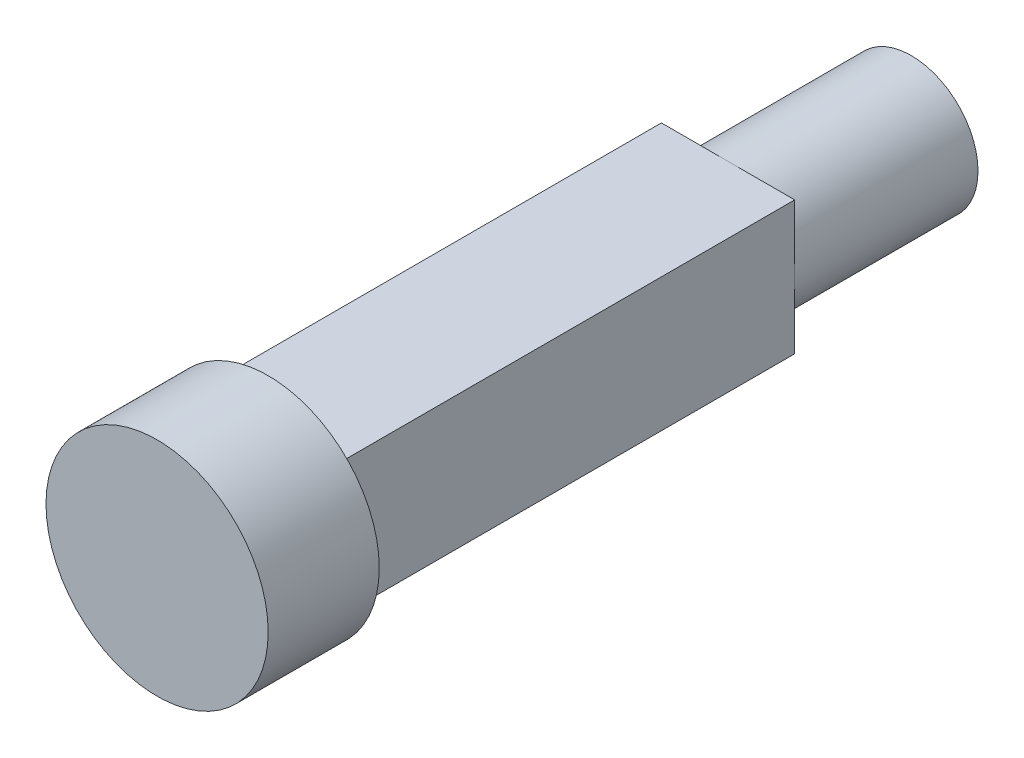
from build123d import *

# Parameters (mm, degrees)
ESQUISSE6_W             = 6
ESQUISSE6_H             = 6
BOSS_EXTRU_2_DEPTH      = 20.7
ENL_V_MAT_EXTRU_1_DEPTH = 10


with BuildPart() as part:
    # Esquisse2 → Révolution1 (revolve)
    with BuildSketch(Plane(origin=(0, 0, 0), x_dir=(0, 0, -1), z_dir=(1, 0, 0))):
        Polygon((0, 0), (33.95, 0), (33.95, 3), (5, 3), (5, 5), (0, 5), align=None)
    revolve(axis=Axis((0, 0, 0), (0, 0, -1)))

    # Esquisse6 → Boss.-Extru.2 (add)
    with BuildSketch(Plane(origin=(0, 0, -5), x_dir=(-1, 0, 0), z_dir=(0, 0, -1))):
        Rectangle(ESQUISSE6_W, ESQUISSE6_H)
    extrude(amount=BOSS_EXTRU_2_DEPTH)

    # Esquisse4 → Enlèv. mat.-Extru.1 (cut)
    with BuildSketch(Plane(origin=(0, 0, -33.95), x_dir=(-1, 0, 0), z_dir=(0, 0, -1))):
        with BuildLine():
            Line((-1.204159458, 1.2), (1.204159458, 1.2))
            ThreePointArc((1.204159458, 1.2), (0, -1.7), (-1.204159458, 1.2))
        make_face()
    extrude(amount=-ENL_V_MAT_EXTRU_1_DEPTH, mode=Mode.SUBTRACT)


solid = part.part
